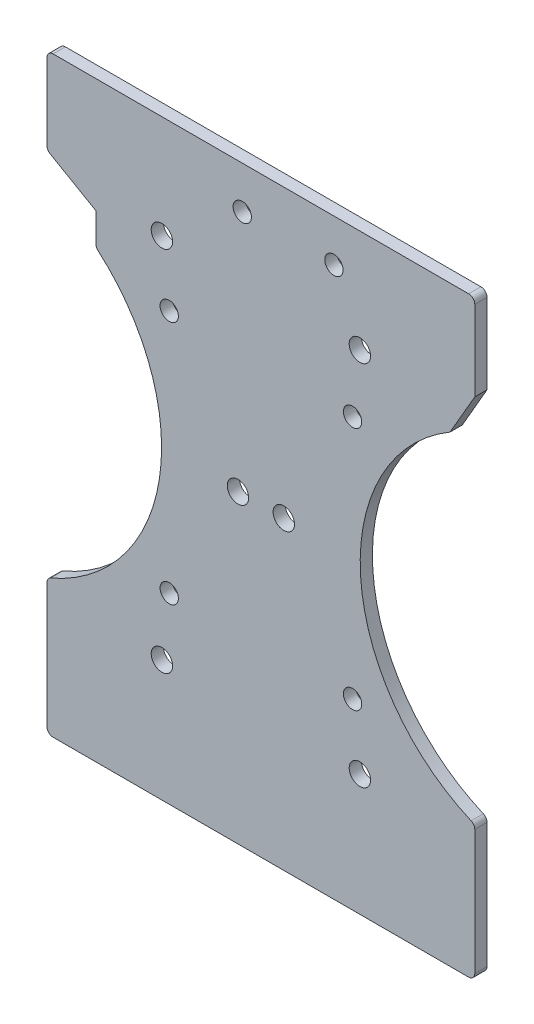
from build123d import *

# Parameters (mm, degrees)
SKETCH_1_R          = 1.75
SKETCH_1_R_2        = 1.5
EXTRUDE_1_DEPTH     = 2
SKETCH_2_W          = 27.7
SKETCH_2_H          = 5
CUT_EXTRUDE_1_DEPTH = 10
SKETCH_3_R          = 1.5
CUT_EXTRUDE_2_DEPTH = 10
SKETCH_4_W          = 70
SKETCH_4_H          = 3
EXTRUDE_2_DEPTH     = 2
FILLET_1_R          = 1


with BuildPart() as part:
    # 草图1 → 凸台-拉伸1 (new body)
    with BuildSketch(Plane.XY):
        with BuildLine():
            Line((-35, -27.810744327), (-35, -46.920144927))
            Line((-35, -46.920144927), (35, -46.920144927))
            Line((35, -46.920144927), (35, -27.810744327))
            ThreePointArc((35, -27.810744327), (16.334866743, -2.254950607), (30.958156738, 25.81006644))
            Line((30.958156738, 25.81006644), (35, 32.810744327))
            Line((35, 32.810744327), (35, 46.920144927))
            Line((35, 46.920144927), (16.8, 46.920144927))
            Line((16.8, 46.920144927), (16.8, 51.920144927))
            Line((16.8, 51.920144927), (-10.9, 51.920144927))
            Line((-10.9, 51.920144927), (-10.9, 46.920144927))
            Line((-10.9, 46.920144927), (-35, 46.920144927))
            Line((-35, 46.920144927), (-35, 32.810744327))
            Line((-35, 32.810744327), (-27, 28.191942173))
            Line((-27, 28.191942173), (-27, 23.009508904))
            ThreePointArc((-27, 23.009508904), (-16.614935725, -4.665079356), (-35, -27.810744327))
        make_face()
        with Locations((-16.1979618, -30.0520382)):
            Circle(SKETCH_1_R, mode=Mode.SUBTRACT)
        with Locations((-3.75, 0)):
            Circle(SKETCH_1_R, mode=Mode.SUBTRACT)
        with Locations((16.1979618, -30.0520382)):
            Circle(SKETCH_1_R, mode=Mode.SUBTRACT)
        with Locations((3.75, 0)):
            Circle(SKETCH_1_R, mode=Mode.SUBTRACT)
        with Locations((-16.1979618, 30.0520382)):
            Circle(SKETCH_1_R, mode=Mode.SUBTRACT)
        with Locations((-3.05, 40)):
            Circle(SKETCH_1_R_2, mode=Mode.SUBTRACT)
        with Locations((16.1979618, 30.0520382)):
            Circle(SKETCH_1_R, mode=Mode.SUBTRACT)
        with Locations((11.95, 40)):
            Circle(SKETCH_1_R_2, mode=Mode.SUBTRACT)
    extrude(amount=EXTRUDE_1_DEPTH)

    # 草图2 → 切除-拉伸1 (cut)
    with BuildSketch(Plane(origin=(0, 0, 0), x_dir=(-1, 0, 0), z_dir=(0, 0, -1))):
        with Locations((-2.95, 49.420144927)):
            Rectangle(SKETCH_2_W, SKETCH_2_H)
    extrude(amount=-CUT_EXTRUDE_1_DEPTH, mode=Mode.SUBTRACT)

    # 草图3 → 切除-拉伸2 (cut)
    with BuildSketch(Plane(origin=(0, 0, 0), x_dir=(-1, 0, 0), z_dir=(0, 0, -1))):
        with Locations((-15, 20)):
            Circle(SKETCH_3_R)
        with Locations((15, 20)):
            Circle(SKETCH_3_R)
        with Locations((15, -20)):
            Circle(SKETCH_3_R)
        with Locations((-15, -20)):
            Circle(SKETCH_3_R)
    extrude(amount=-CUT_EXTRUDE_2_DEPTH, mode=Mode.SUBTRACT)

    # 草图4 → 凸台-拉伸2 (add)
    with BuildSketch(Plane(origin=(0, 0, 0), x_dir=(-1, 0, 0), z_dir=(0, 0, -1))):
        with Locations((0, -48.420144927)):
            Rectangle(SKETCH_4_W, SKETCH_4_H)
    extrude(amount=-EXTRUDE_2_DEPTH)

    # 圆角1
    fillet_1_edges = [part.edges().sort_by_distance(p)[0] for p in [
        (35, -49.920144927, 1),
        (-35, -49.920144927, 1),
        (35, -27.810744327, 1),
        (-35, -27.810744327, 1),
        (-27, 23.009508904, 1),
        (-35, 32.810744327, 1),
        (-35, 46.920144927, 1),
        (35, 46.920144927, 1),
    ]]
    fillet(fillet_1_edges, radius=FILLET_1_R)


solid = part.part
